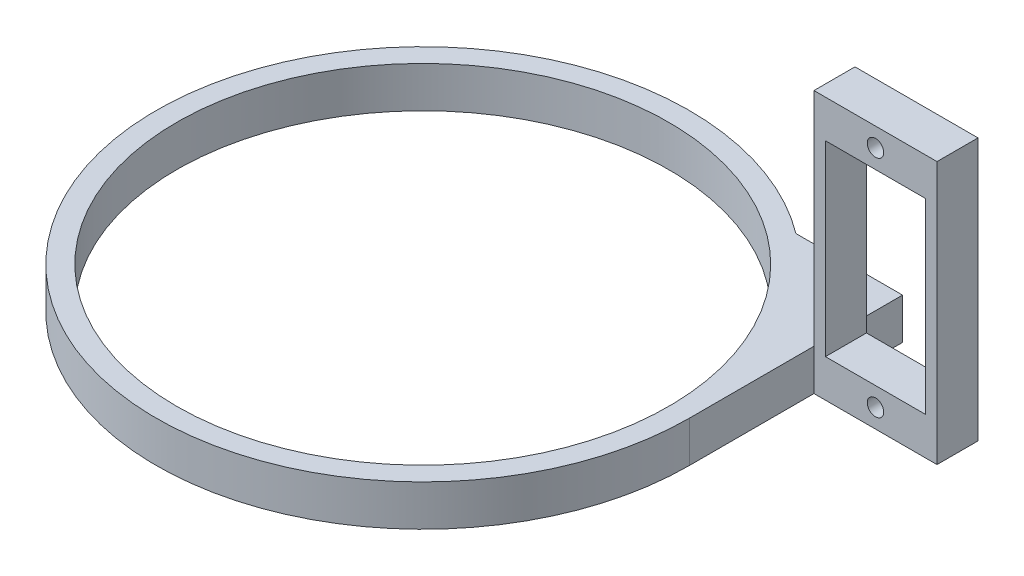
from build123d import *

# Parameters (mm, degrees)
SKETCH1_R           = 30
BOSS_EXTRUDE1_DEPTH = 5
BOSS_EXTRUDE4_START = -20.2
SKETCH3_W           = 15
SKETCH3_H           = 32
SKETCH3_R           = 1
SKETCH3_W_2         = 12.2
SKETCH3_H_2         = 22.8
BOSS_EXTRUDE4_DEPTH = 5


with BuildPart() as part:
    # Sketch1 → Boss-Extrude1 (new body)
    with BuildSketch(Plane(origin=(0, 0, 0), x_dir=(1, 0, 0), z_dir=(0, 1, 0))):
        with BuildLine():
            Line((32.5, 0), (32.5, 26))
            Line((32.5, 26), (19.5, 26))
            ThreePointArc((19.5, 26), (-29.068883707, -14.534441854), (32.5, 0))
        make_face()
        Circle(SKETCH1_R, mode=Mode.SUBTRACT)
    extrude(amount=BOSS_EXTRUDE1_DEPTH)

    # Sketch3 → Boss-Extrude4 (add)
    with BuildSketch(Plane.XY.offset(BOSS_EXTRUDE4_START)):
        with Locations((40, 16)):
            Rectangle(SKETCH3_W, SKETCH3_H)
        with Locations((40, 29.7)):
            Circle(SKETCH3_R, mode=Mode.SUBTRACT)
        with Locations((40, 2.3)):
            Circle(SKETCH3_R, mode=Mode.SUBTRACT)
        with Locations((40, 16)):
            Rectangle(SKETCH3_W_2, SKETCH3_H_2, mode=Mode.SUBTRACT)
    extrude(amount=BOSS_EXTRUDE4_DEPTH)


solid = part.part
